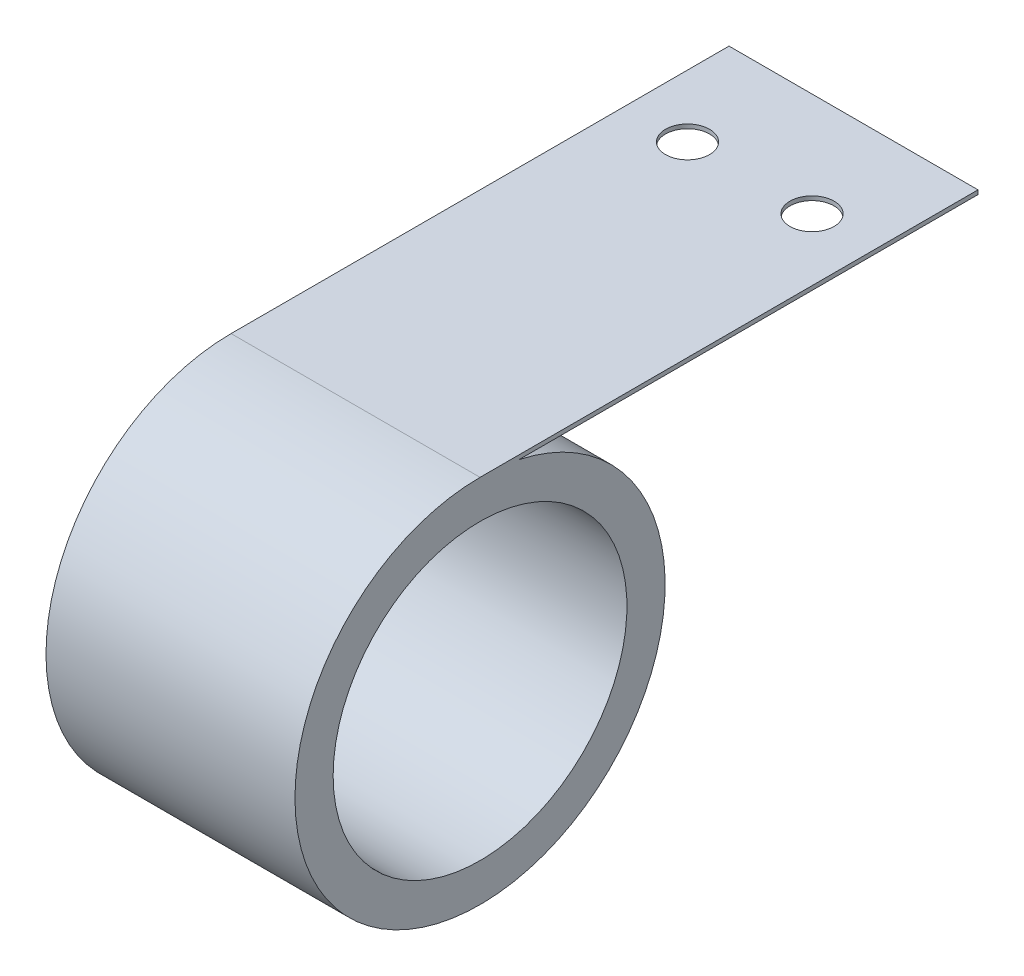
from build123d import *

# Parameters (mm, degrees)
SKETCH1_R           = 22.479
BOSS_EXTRUDE1_DEPTH = 19.05
TWOHOLE_REACH       = 98.838
SKETCH4_R           = 3.3655


with BuildPart() as part:
    # Sketch1 → Boss-Extrude1 (new, symmetric)
    with BuildSketch(Plane(origin=(0, 0, 0), x_dir=(0, 0, -1), z_dir=(1, 0, 0))):
        with BuildLine():
            Line((0, 28.321), (76.2, 28.321))
            Line((76.2, 28.321), (76.2, 27.686))
            Line((76.2, 27.686), (5.963593296, 27.686))
            ThreePointArc((5.963593296, 27.686), (-2.998652614, -28.161802561), (0, 28.321))
        make_face()
        with Locations(Location((0, 0, 0), (0, 0, 180))):
            Circle(SKETCH1_R, mode=Mode.SUBTRACT)
    extrude(amount=BOSS_EXTRUDE1_DEPTH, both=True)

    # Sketch4 → TwoHole (cut, up to next)
    with BuildSketch(Plane(origin=(0, 28.321, 0), x_dir=(1, 0, 0), z_dir=(0, 1, 0)), mode=Mode.PRIVATE) as twohole_sk1:
        with Locations(Location((-9.525, 60.325, 0), (0, 0, 270))):
            Circle(SKETCH4_R)
    twohole_tool1 = extrude(twohole_sk1.sketch, amount=-TWOHOLE_REACH, mode=Mode.PRIVATE) & part.part
    # Sketch4 → TwoHole (cut, up to next)
    with BuildSketch(Plane(origin=(0, 28.321, 0), x_dir=(1, 0, 0), z_dir=(0, 1, 0)), mode=Mode.PRIVATE) as twohole_sk2:
        with Locations(Location((9.525, 60.325, 0), (0, 0, 270))):
            Circle(SKETCH4_R)
    twohole_tool2 = extrude(twohole_sk2.sketch, amount=-TWOHOLE_REACH, mode=Mode.PRIVATE) & part.part
    add(twohole_tool1.solids().sort_by_distance((-9.525, 28.321, -60.325))[0], mode=Mode.SUBTRACT)
    add(twohole_tool2.solids().sort_by_distance((9.525, 28.321, -60.325))[0], mode=Mode.SUBTRACT)


solid = part.part
